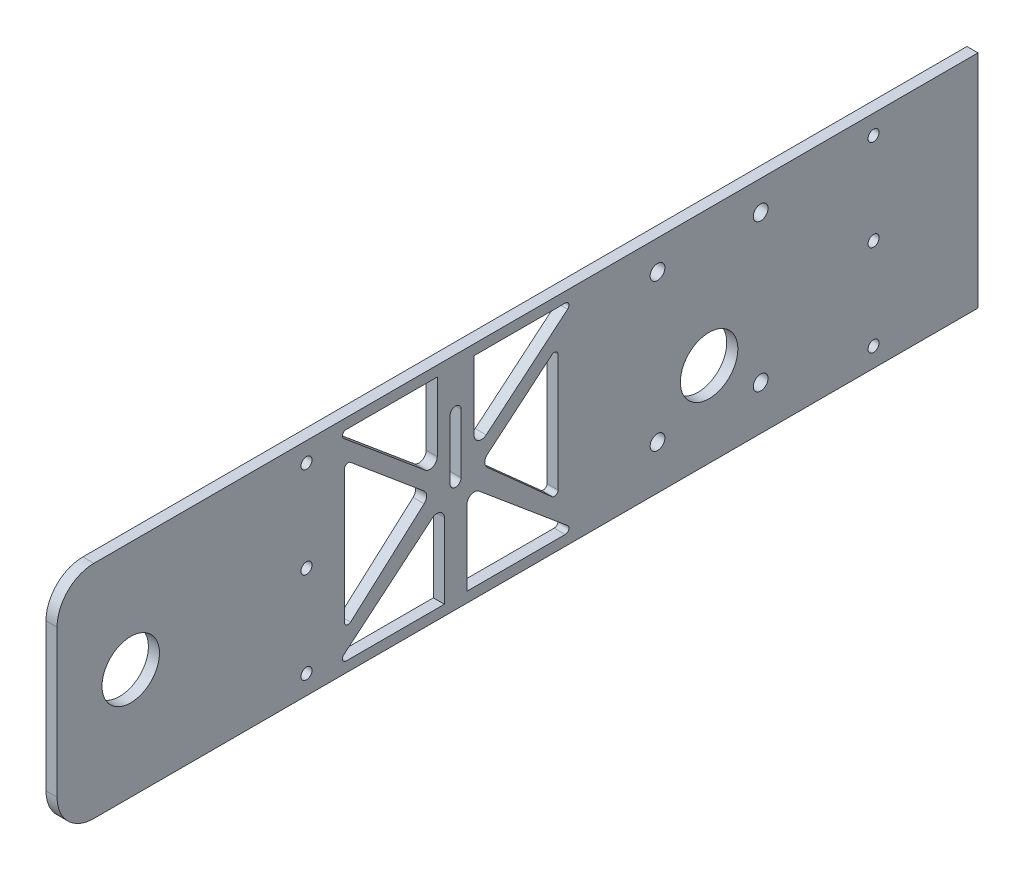
from build123d import *

# Parameters (mm, degrees)
SKETCH1_W           = 3
SKETCH1_H           = 60
BOSS_EXTRUDE1_DEPTH = 250
FILLET1_R           = 10
FILLET2_R           = 10
SKETCH2_R           = 4.25
CUT_EXTRUDE1_DEPTH  = 4
SKETCH9_R           = 7.8
CUT_EXTRUDE7_DEPTH  = 4
SKETCH11_R          = 7.8
CUT_EXTRUDE8_DEPTH  = 4
SKETCH13_R          = 2
CUT_EXTRUDE9_DEPTH  = 4
CUT_EXTRUDE13_DEPTH = 10
FILLET3_R           = 2
FILLET4_R           = 1
SKETCH18_R          = 1.5
SKETCH18_R_2        = 1.499999992
CUT_EXTRUDE15_DEPTH = 4
CUT_EXTRUDE16_DEPTH = 4


with BuildPart() as part:
    # Sketch1 → Boss-Extrude1 (new body)
    with BuildSketch(Plane.XY):
        Rectangle(SKETCH1_W, SKETCH1_H)
    extrude(amount=BOSS_EXTRUDE1_DEPTH)

    # Fillet1
    fillet1_edges = [part.edges().sort_by_distance(p)[0] for p in [
        (0, 30, 250),
    ]]
    fillet(fillet1_edges, radius=FILLET1_R)

    # Fillet2
    fillet2_edges = [part.edges().sort_by_distance(p)[0] for p in [
        (0, -30, 250),
    ]]
    fillet(fillet2_edges, radius=FILLET2_R)

    # Sketch2 → Cut-Extrude1 (cut, through all)
    with BuildSketch(Plane.ZY.offset(1.5)):
        with Locations((230, 0)):
            Circle(SKETCH2_R)
    extrude(amount=-CUT_EXTRUDE1_DEPTH, mode=Mode.SUBTRACT)

    # Sketch9 → Cut-Extrude7 (cut, through all)
    with BuildSketch(Plane(origin=(1.5, 0, 0), x_dir=(0, 0, -1), z_dir=(1, 0, 0))):
        with Locations((-230, 0)):
            Circle(SKETCH9_R)
    extrude(amount=-CUT_EXTRUDE7_DEPTH, mode=Mode.SUBTRACT)

    # Sketch11 → Cut-Extrude8 (cut, through all)
    with BuildSketch(Plane.ZY.offset(1.5)):
        with Locations((73, -7)):
            Circle(SKETCH11_R)
    extrude(amount=-CUT_EXTRUDE8_DEPTH, mode=Mode.SUBTRACT)

    # Sketch13 → Cut-Extrude9 (cut, through all)
    with BuildSketch(Plane(origin=(1.5, 0, 0), x_dir=(0, 0, -1), z_dir=(1, 0, 0))):
        with Locations((-87, 22)):
            Circle(SKETCH13_R)
        with Locations((-59, 22)):
            Circle(SKETCH13_R)
        with Locations((-59, -18)):
            Circle(SKETCH13_R)
        with Locations((-87, -18)):
            Circle(SKETCH13_R)
    extrude(amount=-CUT_EXTRUDE9_DEPTH, mode=Mode.SUBTRACT)

    # Sketch16 → Cut-Extrude13 (cut)
    with BuildSketch(Plane(origin=(1.5, 0, 0), x_dir=(0, 0, -1), z_dir=(1, 0, 0))):
        Polygon((-146.788564399, 27.2), (-174.288564399, 27.2), (-146.788564399, 4.184615385), align=None)
        Polygon((-109.288564399, 27.2), (-136.788564399, 27.2), (-136.788564399, 4.184615385), align=None)
        Polygon((-114, -17.994443239), (-114, 18.25689082), (-134.959973954, 0.715004926), align=None)
        Polygon((-148.617154843, 0.715004926), (-171.981755255, 20.269378193), (-171.981755255, -20.140878829), align=None)
        Polygon((-109.288564399, -27.2), (-138.721101597, -2.567230406), (-138.721101597, -27.2), align=None)
        Polygon((-144.856027201, -2.567230406), (-174.288564399, -27.2), (-144.856027201, -27.2), align=None)
    extrude(amount=-CUT_EXTRUDE13_DEPTH, mode=Mode.SUBTRACT)

    # Fillet3
    fillet3_edges = [part.edges().sort_by_distance(p)[0] for p in [
        (0, 0.715004926, 134.959973954),
        (0, -2.567230406, 144.856027201),
        (0, 4.184615385, 146.788564399),
        (0, -2.567230406, 138.721101597),
        (0, 0.715004926, 148.617154843),
        (0, 4.184615385, 136.788564399),
    ]]
    fillet(fillet3_edges, radius=FILLET3_R)

    # Fillet4
    fillet4_edges = [part.edges().sort_by_distance(p)[0] for p in [
        (0, 18.25689082, 114),
        (0, -17.994443239, 114),
        (0, -27.2, 174.288564399),
        (0, 27.2, 174.288564399),
        (0, -27.2, 109.288564399),
        (0, 20.269378193, 171.981755255),
        (0, -20.140878829, 171.981755255),
        (0, 27.2, 109.288564399),
    ]]
    fillet(fillet4_edges, radius=FILLET4_R)

    # Sketch18 → Cut-Extrude15 (cut, through all)
    with BuildSketch(Plane.ZY.offset(1.5)):
        with Locations((182.288564399, 24.750000007)):
            Circle(SKETCH18_R)
        with Locations((182.288564399, 7e-09)):
            Circle(SKETCH18_R)
        with Locations((182.288564399, -24.749999993)):
            Circle(SKETCH18_R)
        with Locations((28.351822221, 24.750000005)):
            Circle(SKETCH18_R_2)
        with Locations((28.351822214, 0)):
            Circle(SKETCH18_R)
        with Locations((28.351822221, -24.749999995)):
            Circle(SKETCH18_R_2)
    extrude(amount=-CUT_EXTRUDE15_DEPTH, mode=Mode.SUBTRACT)

    # Sketch22 → Cut-Extrude16 (cut, through all)
    with BuildSketch(Plane(origin=(1.5, 0, 0), x_dir=(0, 0, -1), z_dir=(1, 0, 0))):
        with BuildLine():
            Line((-140.3152575, 16.383557477), (-140.3152575, 0.290513908))
            ThreePointArc((-140.3152575, 0.290513908), (-141.8152575, -1.209486092), (-143.3152575, 0.290513908))
            Line((-143.3152575, 0.290513908), (-143.3152575, 16.383557477))
            ThreePointArc((-143.3152575, 16.383557477), (-141.8152575, 17.883557477), (-140.3152575, 16.383557477))
        make_face()
    extrude(amount=-CUT_EXTRUDE16_DEPTH, mode=Mode.SUBTRACT)


solid = part.part
